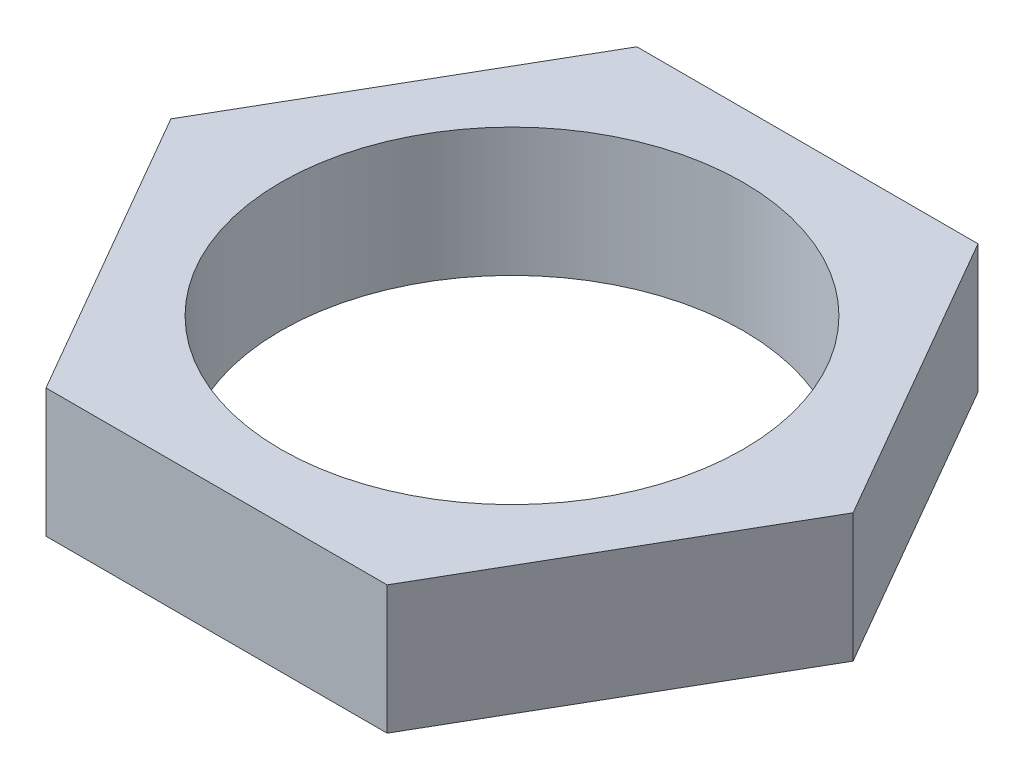
from build123d import *

# Parameters (mm, degrees)
SKETCH1_R           = 9
BOSS_EXTRUDE1_DEPTH = 5


with BuildPart() as part:
    # Sketch1 → Boss-Extrude1 (new body)
    with BuildSketch(Plane(origin=(0, 0, 0), x_dir=(1, 0, 0), z_dir=(0, 1, 0))):
        Polygon((13.279056191, 0), (6.639528096, 11.5), (-6.639528096, 11.5), (-13.279056191, 0), (-6.639528096, -11.5), (6.639528096, -11.5), align=None)
        Circle(SKETCH1_R, mode=Mode.SUBTRACT)
    extrude(amount=BOSS_EXTRUDE1_DEPTH)


solid = part.part
